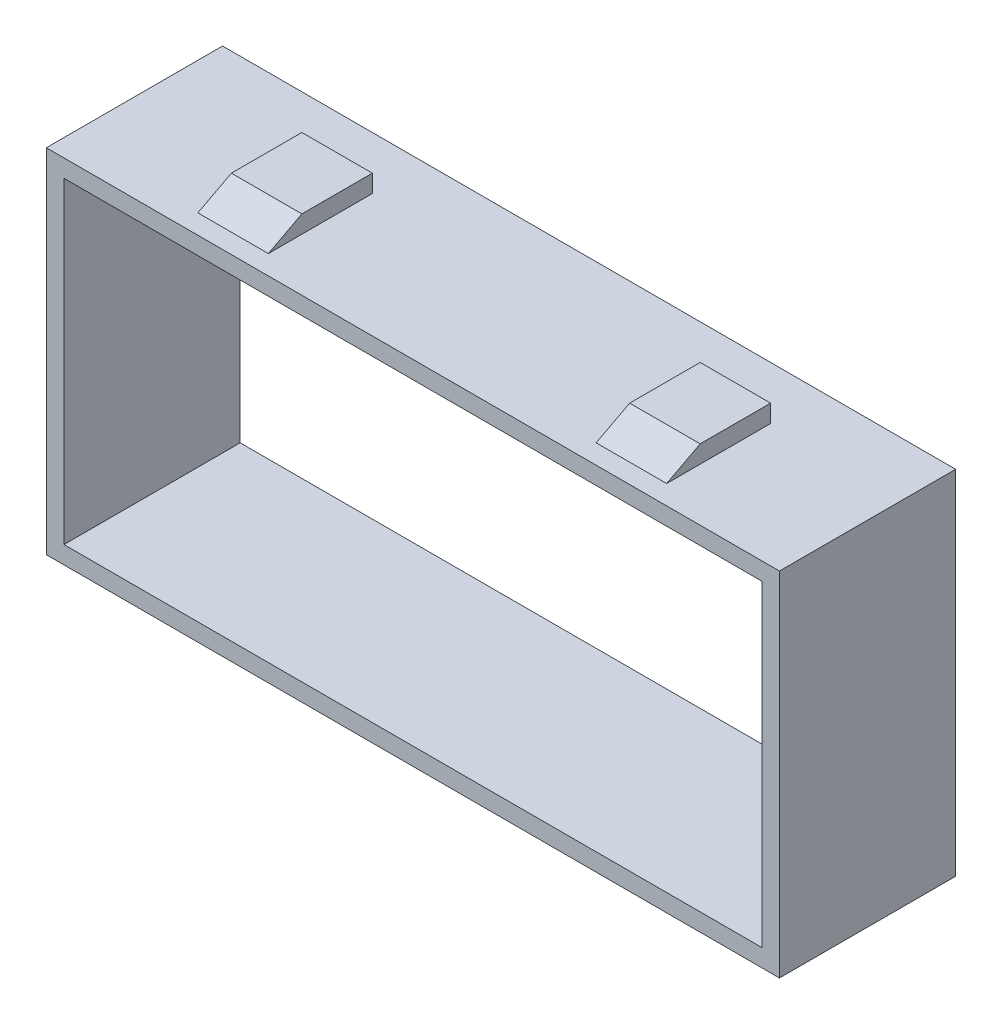
from build123d import *

# Parameters (mm, degrees)
SKETCH1_W           = 41.6
SKETCH1_H           = 20
SKETCH1_W_2         = 39.6
SKETCH1_H_2         = 18
BOSS_EXTRUDE2_DEPTH = 10
SKETCH2_W           = 4
SKETCH2_H           = 10
BOSS_EXTRUDE3_DEPTH = 1
SKETCH3_W           = 3
SKETCH3_H           = 1
CUT_EXTRUDE1_DEPTH  = 27
SKETCH4_W           = 4
SKETCH4_H           = 10
BOSS_EXTRUDE4_DEPTH = 1
SKETCH5_W           = 3
SKETCH5_H           = 1
CUT_EXTRUDE2_DEPTH  = 27


with BuildPart() as part:
    # Sketch1 → Boss-Extrude2 (new body)
    with BuildSketch(Plane.XY):
        Rectangle(SKETCH1_W, SKETCH1_H)
        Rectangle(SKETCH1_W_2, SKETCH1_H_2, mode=Mode.SUBTRACT)
    extrude(amount=BOSS_EXTRUDE2_DEPTH)

    # Sketch2 → Boss-Extrude3 (add)
    with BuildSketch(Plane.XZ.offset(10)):
        with Locations((-11.3, 5)):
            Rectangle(SKETCH2_W, SKETCH2_H)
        with Locations((11.3, 5)):
            Rectangle(SKETCH2_W, SKETCH2_H)
    extrude(amount=BOSS_EXTRUDE3_DEPTH)

    # Sketch3 → Cut-Extrude1 (cut)
    with BuildSketch(Plane.ZY.offset(13.3)):
        Polygon((8.900149248, -10), (7, -11), (10, -11), (10, -10), align=None)
        with Locations((1.5, -10.5)):
            Rectangle(SKETCH3_W, SKETCH3_H)
    extrude(amount=-CUT_EXTRUDE1_DEPTH, mode=Mode.SUBTRACT)

    # Sketch4 → Boss-Extrude4 (add)
    with BuildSketch(Plane(origin=(0, 10, 0), x_dir=(1, 0, 0), z_dir=(0, 1, 0))):
        with Locations((11.3, -5)):
            Rectangle(SKETCH4_W, SKETCH4_H)
        with Locations((-11.3, -5)):
            Rectangle(SKETCH4_W, SKETCH4_H)
    extrude(amount=BOSS_EXTRUDE4_DEPTH)

    # Sketch5 → Cut-Extrude2 (cut)
    with BuildSketch(Plane(origin=(13.3, 0, 0), x_dir=(0, 0, -1), z_dir=(1, 0, 0))):
        Polygon((-7, 11), (-10, 11), (-10, 10), (-8.900149248, 10), align=None)
        with Locations((-1.5, 10.5)):
            Rectangle(SKETCH5_W, SKETCH5_H)
    extrude(amount=-CUT_EXTRUDE2_DEPTH, mode=Mode.SUBTRACT)


solid = part.part
